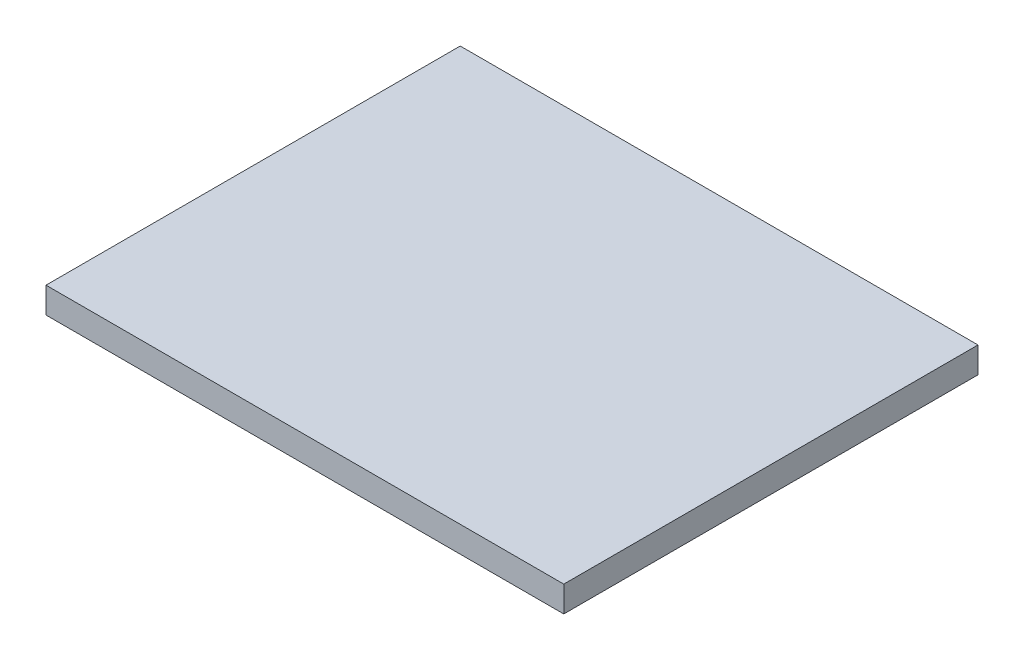
from build123d import *

# Parameters (mm, degrees)
SKETCH1_W           = 127
SKETCH1_H           = 101.6
SKETCH1_W_2         = 114.3
SKETCH1_H_2         = 88.9
BOSS_EXTRUDE1_DEPTH = 6.35
SKETCH1_2_W         = 114.3
SKETCH1_2_H         = 88.9
BOSS_EXTRUDE2_DEPTH = 6.35


with BuildPart() as part:
    # Sketch1 → Boss-Extrude1 (new body)
    with BuildSketch(Plane(origin=(0, 0, 0), x_dir=(1, 0, 0), z_dir=(0, 1, 0))):
        Rectangle(SKETCH1_W, SKETCH1_H)
        Rectangle(SKETCH1_W_2, SKETCH1_H_2, mode=Mode.SUBTRACT)
    extrude(amount=BOSS_EXTRUDE1_DEPTH)

    # Sketch1_2 → Boss-Extrude2 (add)
    with BuildSketch(Plane(origin=(0, 0, 0), x_dir=(1, 0, 0), z_dir=(0, 1, 0))):
        Rectangle(SKETCH1_2_W, SKETCH1_2_H)
    extrude(amount=BOSS_EXTRUDE2_DEPTH)


solid = part.part
